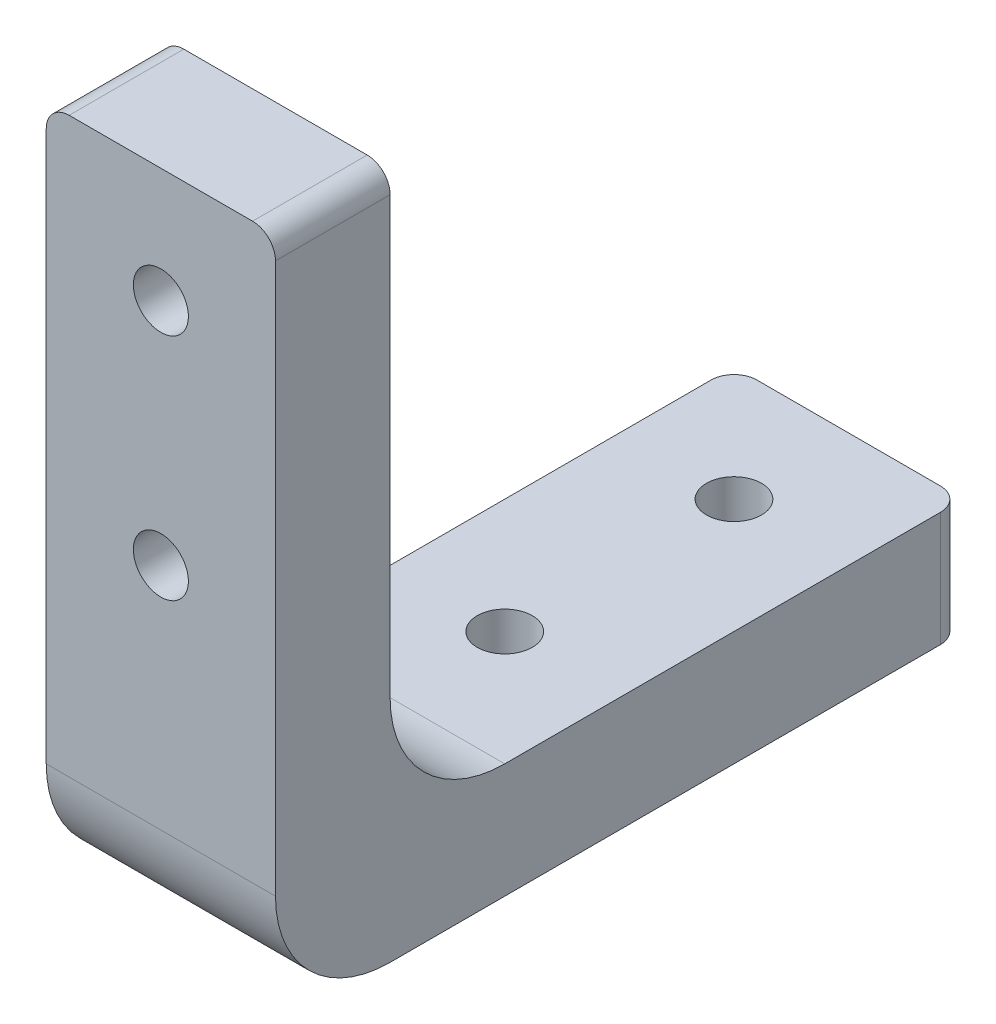
from build123d import *

# Parameters (mm, degrees)
EXTRUDE_1_DEPTH      = 5
EXTRUDE_1_DEPTH_BACK = 5
SKETCH_2_R           = 1.2
CUT_EXTRUDE_1_DEPTH  = 40.37003937
SKETCH_3_R           = 1.2
CUT_EXTRUDE_2_DEPTH  = 40.37003937
FILLET_1_R           = 1
FILLET_2_R           = 5


with BuildPart() as part:
    # Эскиз1 → Бобышка-Вытянуть1 (new, two sides: drawn at the far end of the back side and taken through both)
    with BuildSketch(Plane(origin=(0, 0, 0), x_dir=(0, 0, -1), z_dir=(1, 0, 0)).offset(-EXTRUDE_1_DEPTH_BACK)):
        Polygon((0, 30), (0, 0), (30, 0), (30, 5), (5, 5), (5, 30), align=None)
    extrude(amount=EXTRUDE_1_DEPTH + EXTRUDE_1_DEPTH_BACK)

    # Эскиз2 → Вырез-Вытянуть1 (cut, through all)
    with BuildSketch(Plane(origin=(0, 5, 0), x_dir=(1, 0, 0), z_dir=(0, 1, 0))):
        with Locations((0, 25)):
            Circle(SKETCH_2_R)
        with Locations((0, 15)):
            Circle(SKETCH_2_R)
    extrude(amount=-CUT_EXTRUDE_1_DEPTH, mode=Mode.SUBTRACT)

    # Эскиз3 → Вырез-Вытянуть2 (cut, through all)
    with BuildSketch(Plane(origin=(0, 0, -5), x_dir=(-1, 0, 0), z_dir=(0, 0, -1))):
        with Locations((0, 25)):
            Circle(SKETCH_3_R)
        with Locations((0, 15)):
            Circle(SKETCH_3_R)
    extrude(amount=-CUT_EXTRUDE_2_DEPTH, mode=Mode.SUBTRACT)

    # Скругление1
    fillet_1_edges = [part.edges().sort_by_distance(p)[0] for p in [
        (-5, 2.5, -30),
        (5, 2.5, -30),
        (5, 30, -2.5),
        (-5, 30, -2.5),
    ]]
    fillet(fillet_1_edges, radius=FILLET_1_R)

    # Скругление2
    fillet_2_edges = [part.edges().sort_by_distance(p)[0] for p in [
        (0, 0, 0),
        (0, 5, -5),
    ]]
    fillet(fillet_2_edges, radius=FILLET_2_R)


solid = part.part
